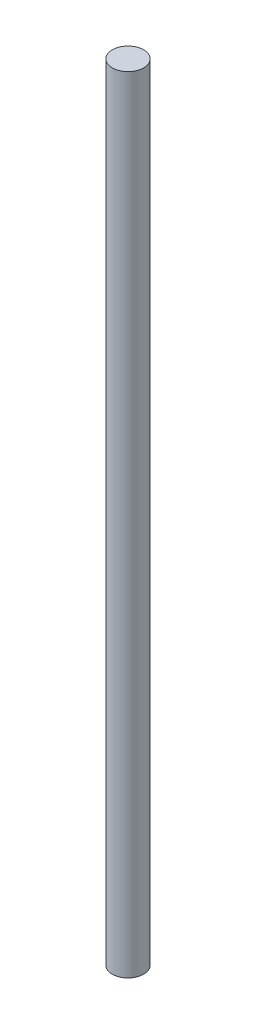
from build123d import *

# Parameters (mm, degrees)
CROQUIS1_R              = 4
SALIENTE_EXTRUIR1_DEPTH = 200


with BuildPart() as part:
    # Croquis1 → Saliente-Extruir1 (new body)
    with BuildSketch(Plane(origin=(0, 0, 0), x_dir=(1, 0, 0), z_dir=(0, 1, 0))):
        Circle(CROQUIS1_R)
    extrude(amount=SALIENTE_EXTRUIR1_DEPTH)


solid = part.part
